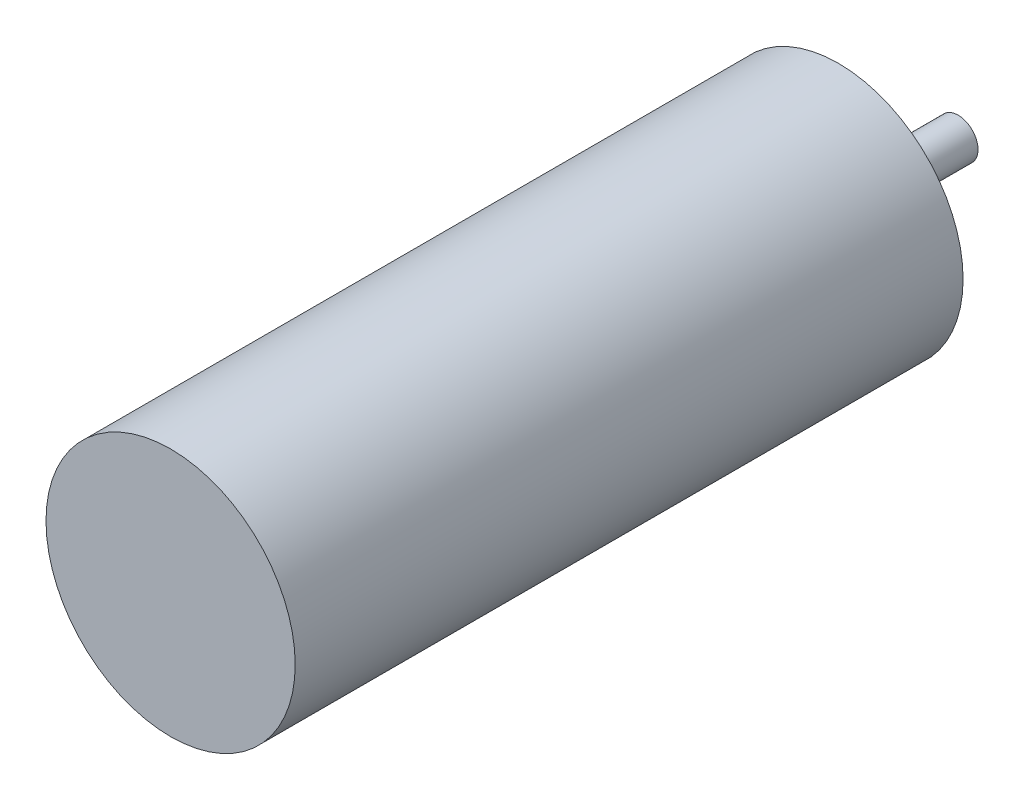
from build123d import *

# Parameters (mm, degrees)
SKETCH1_R           = 12.5
BOSS_EXTRUDE1_DEPTH = 67
SKETCH2_R           = 4
BOSS_EXTRUDE2_DEPTH = 3
SKETCH3_R           = 2
BOSS_EXTRUDE3_DEPTH = 9


with BuildPart() as part:
    # Sketch1 → Boss-Extrude1 (new body)
    with BuildSketch(Plane.XY):
        Circle(SKETCH1_R)
    extrude(amount=BOSS_EXTRUDE1_DEPTH)

    # Sketch2 → Boss-Extrude2 (add)
    with BuildSketch(Plane(origin=(0, 0, 0), x_dir=(-1, 0, 0), z_dir=(0, 0, -1))):
        Circle(SKETCH2_R)
    extrude(amount=BOSS_EXTRUDE2_DEPTH)

    # Sketch3 → Boss-Extrude3 (add)
    with BuildSketch(Plane(origin=(0, 0, -3), x_dir=(-1, 0, 0), z_dir=(0, 0, -1))):
        Circle(SKETCH3_R)
    extrude(amount=BOSS_EXTRUDE3_DEPTH)


solid = part.part
